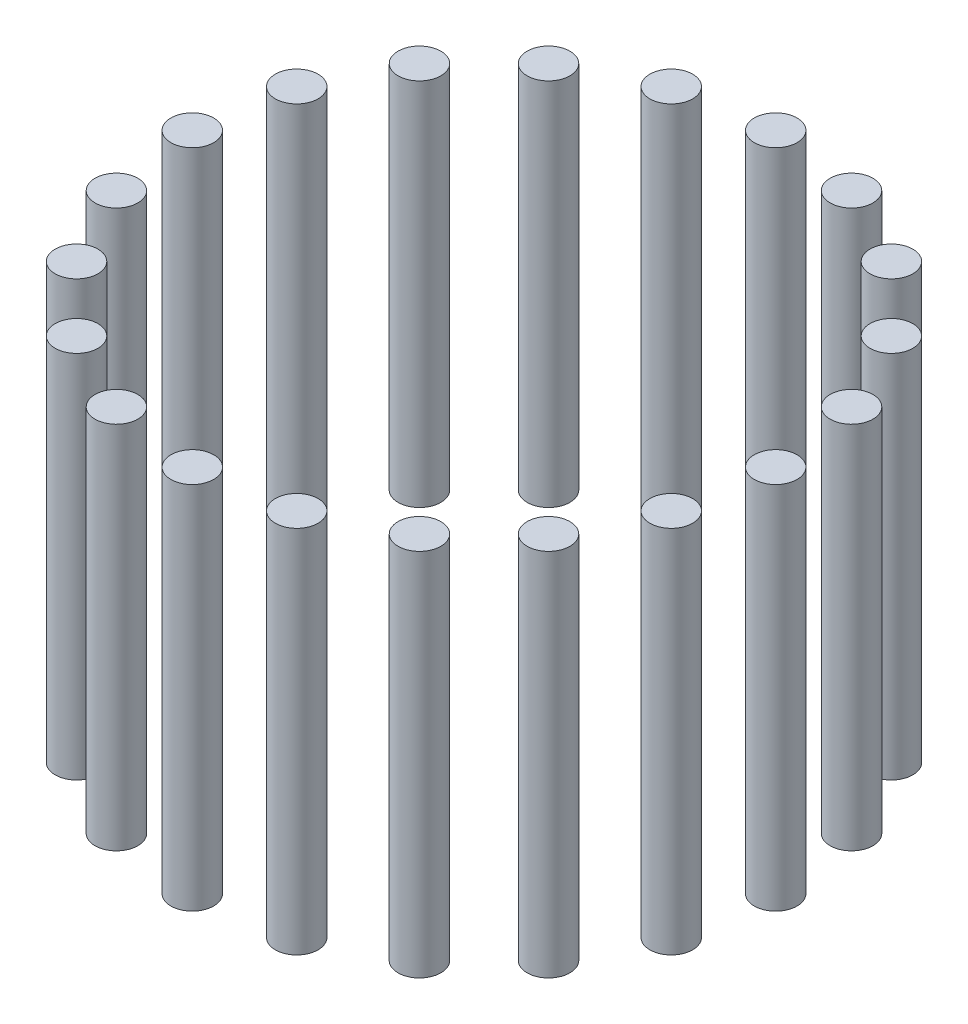
from build123d import *

# Parameters (mm, degrees)
SKETCH1_R              = 5.5
BOSS_EXTRUDE1_DEPTH    = 95
BOSS_EXTRUDE1_2_DEPTH  = 95
BOSS_EXTRUDE1_3_DEPTH  = 95
BOSS_EXTRUDE1_4_DEPTH  = 95
BOSS_EXTRUDE1_5_DEPTH  = 95
BOSS_EXTRUDE1_6_DEPTH  = 95
BOSS_EXTRUDE1_7_DEPTH  = 95
BOSS_EXTRUDE1_8_DEPTH  = 95
BOSS_EXTRUDE1_9_DEPTH  = 95
BOSS_EXTRUDE1_10_DEPTH = 95
BOSS_EXTRUDE1_11_DEPTH = 95
BOSS_EXTRUDE1_12_DEPTH = 95
BOSS_EXTRUDE1_13_DEPTH = 95
BOSS_EXTRUDE1_14_DEPTH = 95
BOSS_EXTRUDE1_15_DEPTH = 95
BOSS_EXTRUDE1_16_DEPTH = 95
BOSS_EXTRUDE1_17_DEPTH = 95
BOSS_EXTRUDE1_18_DEPTH = 95
BOSS_EXTRUDE1_19_DEPTH = 95
BOSS_EXTRUDE1_20_DEPTH = 95


with BuildPart() as part:
    # Sketch1 → Boss-Extrude1 (new body)
    with BuildSketch(Plane(origin=(0, 0, 0), x_dir=(1, 0, 0), z_dir=(0, 1, 0))):
        with Locations((-75, 0)):
            Circle(SKETCH1_R)
    extrude(amount=BOSS_EXTRUDE1_DEPTH)


with BuildPart() as body_2:
    # Sketch1 → Boss-Extrude1 2 (new body)
    with BuildSketch(Plane(origin=(0, 0, 0), x_dir=(1, 0, 0), z_dir=(0, 1, 0))):
        with Locations((-71.329238722, 23.176274578)):
            Circle(SKETCH1_R)
    extrude(amount=BOSS_EXTRUDE1_2_DEPTH)


with BuildPart() as body_3:
    # Sketch1 → Boss-Extrude1 3 (new body)
    with BuildSketch(Plane(origin=(0, 0, 0), x_dir=(1, 0, 0), z_dir=(0, 1, 0))):
        with Locations((-60.676274578, 44.083893922)):
            Circle(SKETCH1_R)
    extrude(amount=BOSS_EXTRUDE1_3_DEPTH)


with BuildPart() as body_4:
    # Sketch1 → Boss-Extrude1 4 (new body)
    with BuildSketch(Plane(origin=(0, 0, 0), x_dir=(1, 0, 0), z_dir=(0, 1, 0))):
        with Locations((-44.083893922, 60.676274578)):
            Circle(SKETCH1_R)
    extrude(amount=BOSS_EXTRUDE1_4_DEPTH)


with BuildPart() as body_5:
    # Sketch1 → Boss-Extrude1 5 (new body)
    with BuildSketch(Plane(origin=(0, 0, 0), x_dir=(1, 0, 0), z_dir=(0, 1, 0))):
        with Locations((-23.176274578, 71.329238722)):
            Circle(SKETCH1_R)
    extrude(amount=BOSS_EXTRUDE1_5_DEPTH)


with BuildPart() as body_6:
    # Sketch1 → Boss-Extrude1 6 (new body)
    with BuildSketch(Plane(origin=(0, 0, 0), x_dir=(1, 0, 0), z_dir=(0, 1, 0))):
        with Locations((0, 75)):
            Circle(SKETCH1_R)
    extrude(amount=BOSS_EXTRUDE1_6_DEPTH)


with BuildPart() as body_7:
    # Sketch1 → Boss-Extrude1 7 (new body)
    with BuildSketch(Plane(origin=(0, 0, 0), x_dir=(1, 0, 0), z_dir=(0, 1, 0))):
        with Locations((23.176274578, 71.329238722)):
            Circle(SKETCH1_R)
    extrude(amount=BOSS_EXTRUDE1_7_DEPTH)


with BuildPart() as body_8:
    # Sketch1 → Boss-Extrude1 8 (new body)
    with BuildSketch(Plane(origin=(0, 0, 0), x_dir=(1, 0, 0), z_dir=(0, 1, 0))):
        with Locations((44.083893922, 60.676274578)):
            Circle(SKETCH1_R)
    extrude(amount=BOSS_EXTRUDE1_8_DEPTH)


with BuildPart() as body_9:
    # Sketch1 → Boss-Extrude1 9 (new body)
    with BuildSketch(Plane(origin=(0, 0, 0), x_dir=(1, 0, 0), z_dir=(0, 1, 0))):
        with Locations((60.676274578, 44.083893922)):
            Circle(SKETCH1_R)
    extrude(amount=BOSS_EXTRUDE1_9_DEPTH)


with BuildPart() as body_10:
    # Sketch1 → Boss-Extrude1 10 (new body)
    with BuildSketch(Plane(origin=(0, 0, 0), x_dir=(1, 0, 0), z_dir=(0, 1, 0))):
        with Locations((71.329238722, 23.176274578)):
            Circle(SKETCH1_R)
    extrude(amount=BOSS_EXTRUDE1_10_DEPTH)


with BuildPart() as body_11:
    # Sketch1 → Boss-Extrude1 11 (new body)
    with BuildSketch(Plane(origin=(0, 0, 0), x_dir=(1, 0, 0), z_dir=(0, 1, 0))):
        with Locations((75, 0)):
            Circle(SKETCH1_R)
    extrude(amount=BOSS_EXTRUDE1_11_DEPTH)


with BuildPart() as body_12:
    # Sketch1 → Boss-Extrude1 12 (new body)
    with BuildSketch(Plane(origin=(0, 0, 0), x_dir=(1, 0, 0), z_dir=(0, 1, 0))):
        with Locations((71.329238722, -23.176274578)):
            Circle(SKETCH1_R)
    extrude(amount=BOSS_EXTRUDE1_12_DEPTH)


with BuildPart() as body_13:
    # Sketch1 → Boss-Extrude1 13 (new body)
    with BuildSketch(Plane(origin=(0, 0, 0), x_dir=(1, 0, 0), z_dir=(0, 1, 0))):
        with Locations((60.676274578, -44.083893922)):
            Circle(SKETCH1_R)
    extrude(amount=BOSS_EXTRUDE1_13_DEPTH)


with BuildPart() as body_14:
    # Sketch1 → Boss-Extrude1 14 (new body)
    with BuildSketch(Plane(origin=(0, 0, 0), x_dir=(1, 0, 0), z_dir=(0, 1, 0))):
        with Locations((44.083893922, -60.676274578)):
            Circle(SKETCH1_R)
    extrude(amount=BOSS_EXTRUDE1_14_DEPTH)


with BuildPart() as body_15:
    # Sketch1 → Boss-Extrude1 15 (new body)
    with BuildSketch(Plane(origin=(0, 0, 0), x_dir=(1, 0, 0), z_dir=(0, 1, 0))):
        with Locations((23.176274578, -71.329238722)):
            Circle(SKETCH1_R)
    extrude(amount=BOSS_EXTRUDE1_15_DEPTH)


with BuildPart() as body_16:
    # Sketch1 → Boss-Extrude1 16 (new body)
    with BuildSketch(Plane(origin=(0, 0, 0), x_dir=(1, 0, 0), z_dir=(0, 1, 0))):
        with Locations((0, -75)):
            Circle(SKETCH1_R)
    extrude(amount=BOSS_EXTRUDE1_16_DEPTH)


with BuildPart() as body_17:
    # Sketch1 → Boss-Extrude1 17 (new body)
    with BuildSketch(Plane(origin=(0, 0, 0), x_dir=(1, 0, 0), z_dir=(0, 1, 0))):
        with Locations((-23.176274578, -71.329238722)):
            Circle(SKETCH1_R)
    extrude(amount=BOSS_EXTRUDE1_17_DEPTH)


with BuildPart() as body_18:
    # Sketch1 → Boss-Extrude1 18 (new body)
    with BuildSketch(Plane(origin=(0, 0, 0), x_dir=(1, 0, 0), z_dir=(0, 1, 0))):
        with Locations((-44.083893922, -60.676274578)):
            Circle(SKETCH1_R)
    extrude(amount=BOSS_EXTRUDE1_18_DEPTH)


with BuildPart() as body_19:
    # Sketch1 → Boss-Extrude1 19 (new body)
    with BuildSketch(Plane(origin=(0, 0, 0), x_dir=(1, 0, 0), z_dir=(0, 1, 0))):
        with Locations((-60.676274578, -44.083893922)):
            Circle(SKETCH1_R)
    extrude(amount=BOSS_EXTRUDE1_19_DEPTH)


with BuildPart() as body_20:
    # Sketch1 → Boss-Extrude1 20 (new body)
    with BuildSketch(Plane(origin=(0, 0, 0), x_dir=(1, 0, 0), z_dir=(0, 1, 0))):
        with Locations((-71.329238722, -23.176274578)):
            Circle(SKETCH1_R)
    extrude(amount=BOSS_EXTRUDE1_20_DEPTH)


solid = Compound([part.part, body_2.part, body_3.part, body_4.part, body_5.part, body_6.part, body_7.part, body_8.part, body_9.part, body_10.part, body_11.part, body_12.part, body_13.part, body_14.part, body_15.part, body_16.part, body_17.part, body_18.part, body_19.part, body_20.part])
